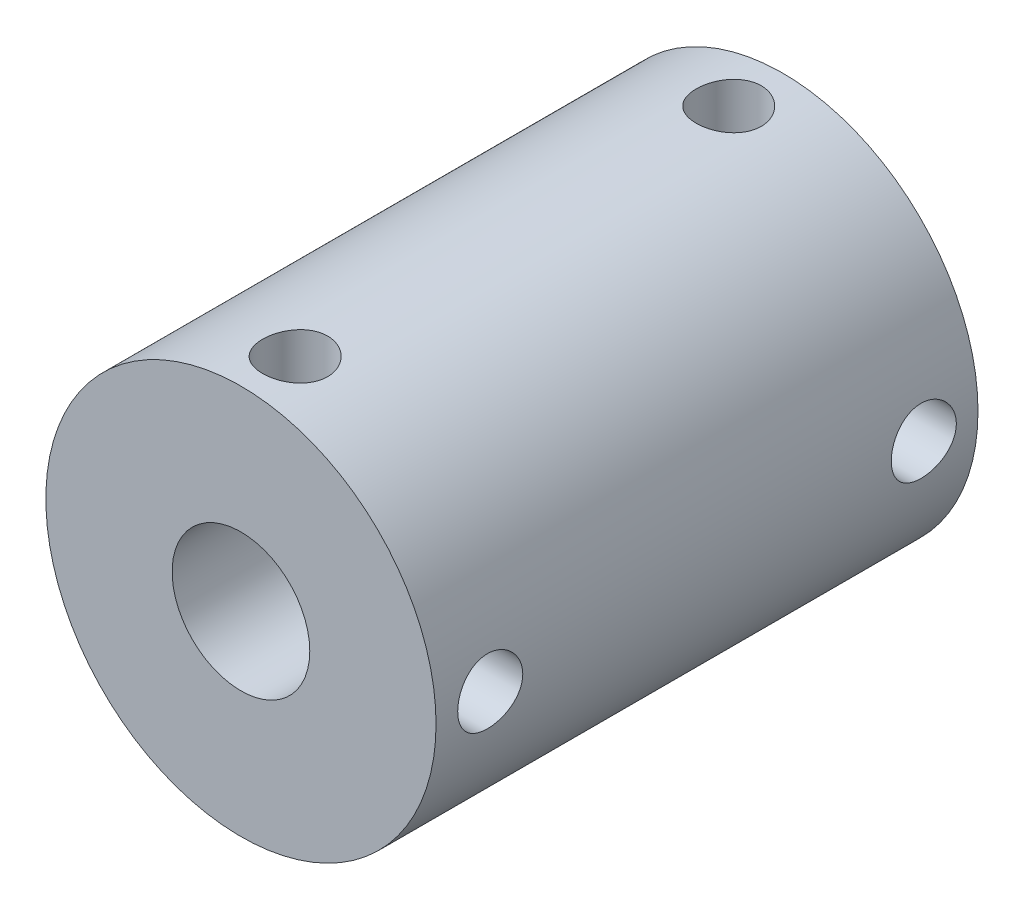
from build123d import *

# Parameters (mm, degrees)
SKETCH1_R           = 9
BOSS_EXTRUDE1_DEPTH = 12.5
SKETCH2_R           = 3.175
CUT_EXTRUDE1_DEPTH  = 26
SKETCH3_R           = 1.5
CUT_EXTRUDE2_DEPTH  = 10
SKETCH4_R           = 1.5
CUT_EXTRUDE3_DEPTH  = 10.0000001


with BuildPart() as part:
    # Sketch1 → Boss-Extrude1 (new body, symmetric)
    with BuildSketch(Plane.XY):
        Circle(SKETCH1_R)
    extrude(amount=BOSS_EXTRUDE1_DEPTH, both=True)

    # Sketch2 → Cut-Extrude1 (cut, through all)
    with BuildSketch(Plane.XY.offset(12.5)):
        Circle(SKETCH2_R)
    extrude(amount=-CUT_EXTRUDE1_DEPTH, mode=Mode.SUBTRACT)

    # Sketch3 → Cut-Extrude2 (cut, through all)
    with BuildSketch(Plane(origin=(0, 0, 0), x_dir=(1, 0, 0), z_dir=(0, 1, 0))):
        with Locations((0, 10)):
            Circle(SKETCH3_R)
        with Locations((0, -10)):
            Circle(SKETCH3_R)
    extrude(amount=CUT_EXTRUDE2_DEPTH, mode=Mode.SUBTRACT)

    # Sketch4 → Cut-Extrude3 (cut, through all)
    with BuildSketch(Plane(origin=(0, 0, 0), x_dir=(0, 0, -1), z_dir=(1, 0, 0))):
        with Locations((-10, 0)):
            Circle(SKETCH4_R)
        with Locations((10, 0)):
            Circle(SKETCH4_R)
    extrude(amount=CUT_EXTRUDE3_DEPTH, mode=Mode.SUBTRACT)


solid = part.part
